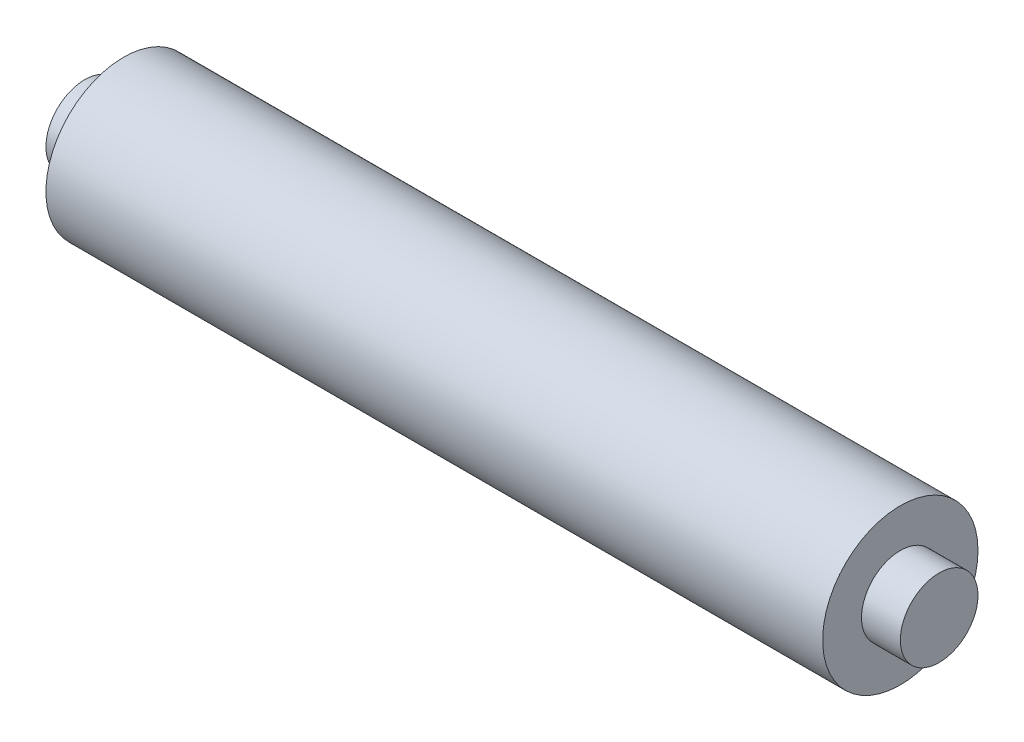
from build123d import *

# Parameters (mm, degrees)
SKETCH1_R           = 76.2
BOSS_EXTRUDE1_DEPTH = 76.2
SKETCH2_R           = 152.4
BOSS_EXTRUDE2_DEPTH = 1524
SKETCH3_R           = 76.2
BOSS_EXTRUDE3_DEPTH = 76.2


with BuildPart() as part:
    # Sketch1 → Boss-Extrude1 (new body)
    with BuildSketch(Plane(origin=(0, 0, 0), x_dir=(0, 0, -1), z_dir=(1, 0, 0))):
        Circle(SKETCH1_R)
    extrude(amount=BOSS_EXTRUDE1_DEPTH)

    # Sketch2 → Boss-Extrude2 (add)
    with BuildSketch(Plane(origin=(76.2, 0, 0), x_dir=(0, 0, -1), z_dir=(1, 0, 0))):
        Circle(SKETCH2_R)
    extrude(amount=BOSS_EXTRUDE2_DEPTH)

    # Sketch3 → Boss-Extrude3 (add)
    with BuildSketch(Plane(origin=(1600.2, 0, 0), x_dir=(0, 0, -1), z_dir=(1, 0, 0))):
        Circle(SKETCH3_R)
    extrude(amount=BOSS_EXTRUDE3_DEPTH)


solid = part.part
